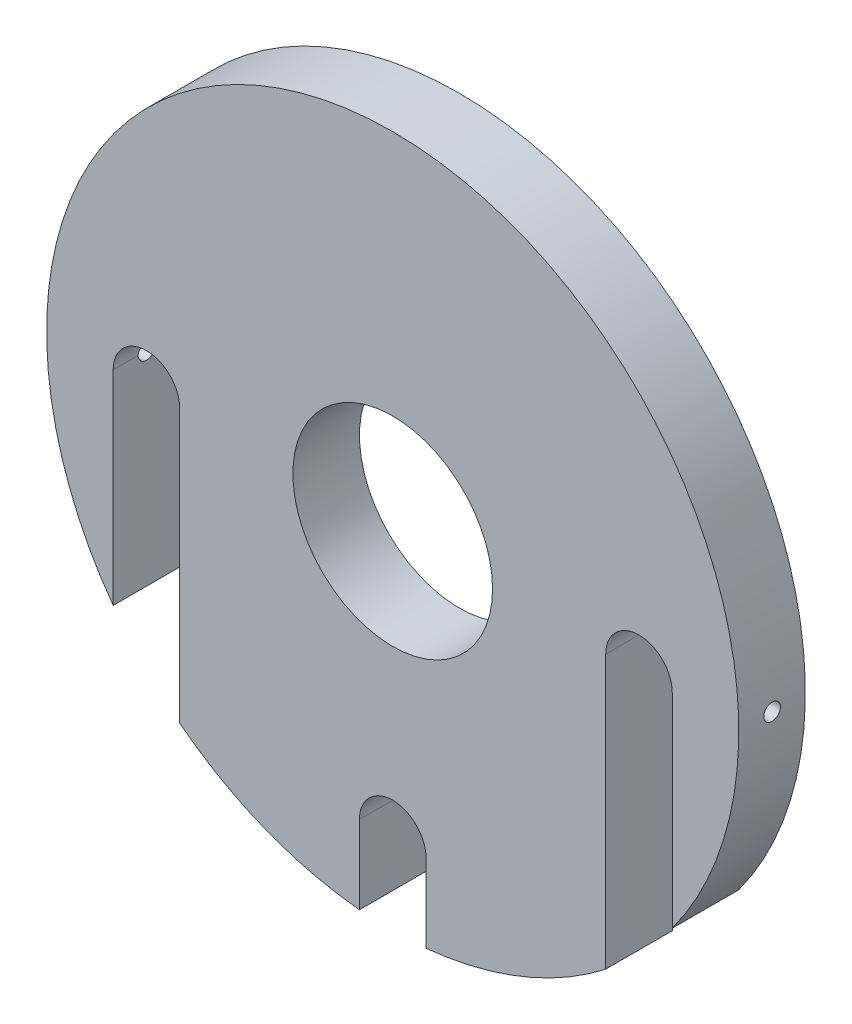
from build123d import *

# Parameters (mm, degrees)
SKETCH1_R              = 52
BOSS_EXTRUDE1_DEPTH    = 10
CUT_EXTRUDE1_DEPTH     = 10
SKETCH3_R              = 15
CUT_EXTRUDE2_DEPTH     = 10
M3_TAPPED_HOLE3_REACH  = 118.705
M3_TAPPED_HOLE3_BORE_R = 1.25


with BuildPart() as part:
    # Sketch1 → Boss-Extrude1 (new body)
    with BuildSketch(Plane.XY):
        Circle(SKETCH1_R)
    extrude(amount=BOSS_EXTRUDE1_DEPTH)

    # Sketch2 → Cut-Extrude1 (cut)
    with BuildSketch(Plane.XY.offset(10)):
        with BuildLine():
            Line((32, 0), (32, -45))
            Line((32, -45), (42, -45))
            Line((42, -45), (42, 3.54e-07))
            ThreePointArc((42, 3.54e-07), (36.999999823, 5), (32, 0))
        make_face()
        with BuildLine():
            Line((-5, -39.999999646), (-5, -55))
            Line((-5, -55), (5, -55))
            Line((5, -55), (5, -40))
            ThreePointArc((5, -40), (1.77e-07, -35), (-5, -39.999999646))
        make_face()
        with BuildLine():
            Line((-32, -45), (-42, -45))
            Line((-42, -45), (-42, 3.54e-07))
            ThreePointArc((-42, 3.54e-07), (-36.999999823, 5), (-32, 0))
            Line((-32, 0), (-32, -45))
        make_face()
    extrude(amount=-CUT_EXTRUDE1_DEPTH, mode=Mode.SUBTRACT)

    # Sketch3 → Cut-Extrude2 (cut)
    with BuildSketch(Plane.XY.offset(10)):
        Circle(SKETCH3_R)
    extrude(amount=-CUT_EXTRUDE2_DEPTH, mode=Mode.SUBTRACT)

    # M3 Tapped Hole3 bore → M3 Tapped Hole3 (cut, up to next)
    with BuildSketch(Plane(origin=(52, 0, 0), x_dir=(0, 0, -1), z_dir=(1, 0, 0)), mode=Mode.PRIVATE) as m3_tapped_hole3_sk1:
        with Locations((-5, 1e-08)):
            Circle(M3_TAPPED_HOLE3_BORE_R)
    m3_tapped_hole3_tool1 = extrude(m3_tapped_hole3_sk1.sketch, amount=-M3_TAPPED_HOLE3_REACH, mode=Mode.PRIVATE) & part.part
    m3_tapped_hole3 = m3_tapped_hole3_tool1.solids().sort_by_distance((52, 0, 5))[0]
    add(m3_tapped_hole3, mode=Mode.SUBTRACT)

    # Mirror1: M3 Tapped Hole3 across plane
    add(m3_tapped_hole3.mirror(Plane(origin=(0, 0, 0), x_dir=(0, 0, 1), z_dir=(1, 0, 0))), mode=Mode.SUBTRACT)


solid = part.part
